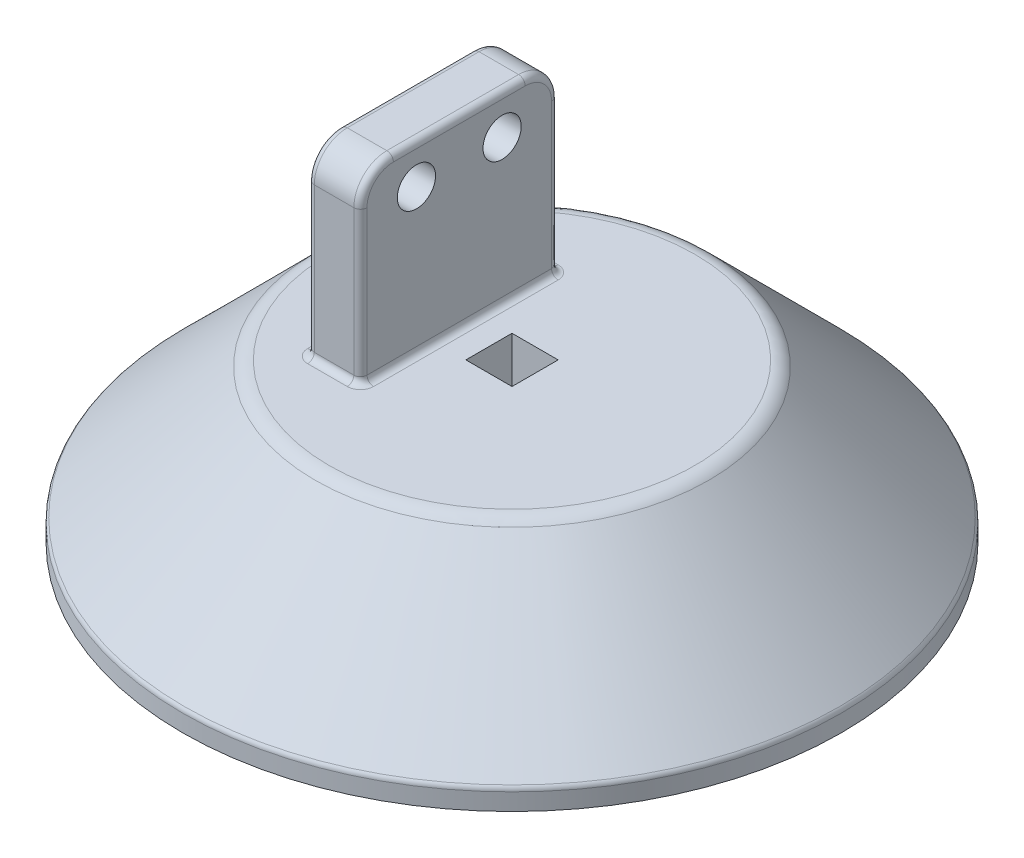
from build123d import *

# Parameters (mm, degrees)
SKETCH2_W           = 8
SKETCH2_H           = 30
BOSS_EXTRUDE1_DEPTH = 28
CUT_EXTRUDE1_REACH  = 52
SKETCH3_R           = 2.9
FILLET1_R           = 5
FILLET2_R           = 3
FILLET3_R           = 1
FILLET4_R           = 1
SKETCH4_W           = 7
SKETCH4_H           = 7
CUT_EXTRUDE2_DEPTH  = 20


with BuildPart() as part:
    # Sketch1 → Revolve1 (revolve)
    with BuildSketch(Plane.XY):
        Polygon((0, 0), (0, 24), (-29, 24), (-50, 3), (-50, 0), align=None)
    revolve(axis=Axis((0, 0, 0), (0, 1, 0)))

    # Sketch2 → Boss-Extrude1 (add)
    with BuildSketch(Plane(origin=(0, 24, 0), x_dir=(1, 0, 0), z_dir=(0, 1, 0))):
        with Locations((-12, 0)):
            Rectangle(SKETCH2_W, SKETCH2_H)
    extrude(amount=BOSS_EXTRUDE1_DEPTH)

    # Sketch3 → Cut-Extrude1 (cut, up to next)
    with BuildSketch(Plane(origin=(0, 0, 0), x_dir=(0, 0, -1), z_dir=(1, 0, 0)), mode=Mode.PRIVATE) as cut_extrude1_sk1:
        with Locations((-6.5, 46)):
            Circle(SKETCH3_R)
    cut_extrude1_tool1 = extrude(cut_extrude1_sk1.sketch, amount=-CUT_EXTRUDE1_REACH, mode=Mode.PRIVATE) & part.part
    add(cut_extrude1_tool1.solids().sort_by_distance((0, 46, 6.5))[0], mode=Mode.SUBTRACT)
    # Sketch3 → Cut-Extrude1 (cut, up to next)
    with BuildSketch(Plane(origin=(0, 0, 0), x_dir=(0, 0, -1), z_dir=(1, 0, 0)), mode=Mode.PRIVATE) as cut_extrude1_sk2:
        with Locations((6.5, 46)):
            Circle(SKETCH3_R)
    cut_extrude1_tool2 = extrude(cut_extrude1_sk2.sketch, amount=-CUT_EXTRUDE1_REACH, mode=Mode.PRIVATE) & part.part
    add(cut_extrude1_tool2.solids().sort_by_distance((0, 46, -6.5))[0], mode=Mode.SUBTRACT)

    # Fillet1
    fillet1_edges = [part.edges().sort_by_distance(p)[0] for p in [
        (-12, 52, 15),
        (-12, 52, -15),
    ]]
    fillet(fillet1_edges, radius=FILLET1_R)

    # Fillet2
    fillet2_edges = [part.edges().sort_by_distance(p)[0] for p in [
        (29, 24, 0),
    ]]
    fillet(fillet2_edges, radius=FILLET2_R)

    # Fillet3
    fillet3_edges = [part.edges().sort_by_distance(p)[0] for p in [
        (50, 3, 0),
    ]]
    fillet(fillet3_edges, radius=FILLET3_R)

    # Fillet4
    fillet4_edges = [part.edges().sort_by_distance(p)[0] for p in [
        (-16, 24, 0),
        (-12, 24, 15),
        (-8, 24, 0),
        (-12, 24, -15),
        (-16, 52, 0),
        (-8, 52, 0),
        (-16, 35.5, 15),
        (-16, 35.5, -15),
        (-16, 50.535533906, 13.535533906),
        (-16, 50.535533906, -13.535533906),
        (-8, 35.5, -15),
        (-8, 35.5, 15),
        (-8, 50.535533906, 13.535533906),
        (-8, 50.535533906, -13.535533906),
    ]]
    fillet(fillet4_edges, radius=FILLET4_R)

    # Sketch4 → Cut-Extrude2 (cut)
    with BuildSketch(Plane(origin=(0, 24, 0), x_dir=(1, 0, 0), z_dir=(0, 1, 0))):
        Rectangle(SKETCH4_W, SKETCH4_H)
    extrude(amount=-CUT_EXTRUDE2_DEPTH, mode=Mode.SUBTRACT)


solid = part.part
